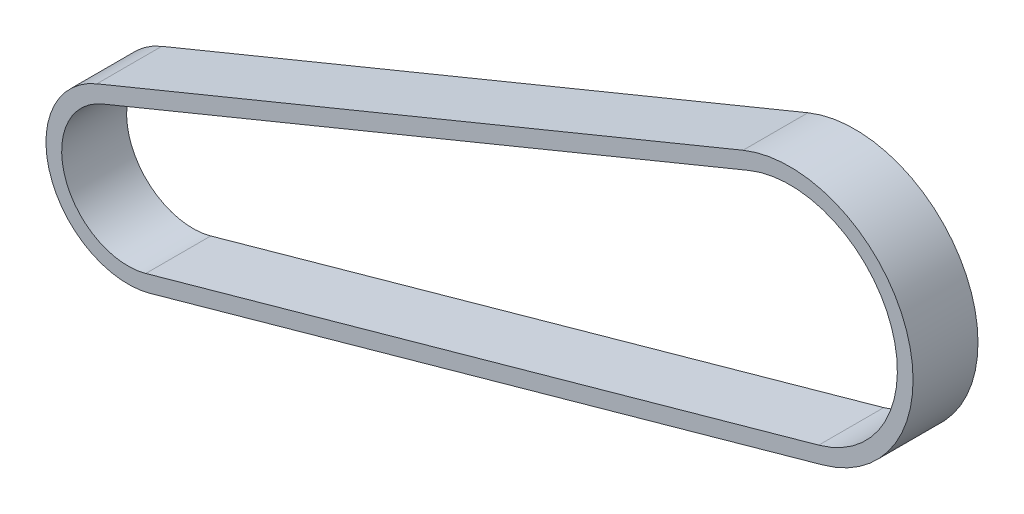
from build123d import *

# Parameters (mm, degrees)
SKETCH3_W = 6
SKETCH3_H = 1.45


with BuildPart() as part:
    # Sweep1: sweep along a path in Sketch2
    with BuildLine(Plane.XY) as sweep1_path:
        Line((-63.479169169, -15.349116299), (-3.775588382, 9.187084379))
        ThreePointArc((-3.775588382, 9.187084379), (9.393349668, 3.228400383), (2.670022327, -9.567056381))
        Line((2.670022327, -9.567056381), (-59.502860815, -26.918578051))
        ThreePointArc((-59.502860815, -26.918578051), (-66.944775787, -23.008250243), (-63.479169169, -15.349116299))
    # Sketch3 → Sweep1 (sweep)
    with BuildSketch(Plane(origin=(-63.479169169, -15.349116299, 0), x_dir=(0, 0, -1), z_dir=(0.9249376555837554, 0.3801188410000567, 0))):
        with Locations((0, 0.725)):
            Rectangle(SKETCH3_W, SKETCH3_H)
    sweep(path=sweep1_path.line)


solid = part.part
